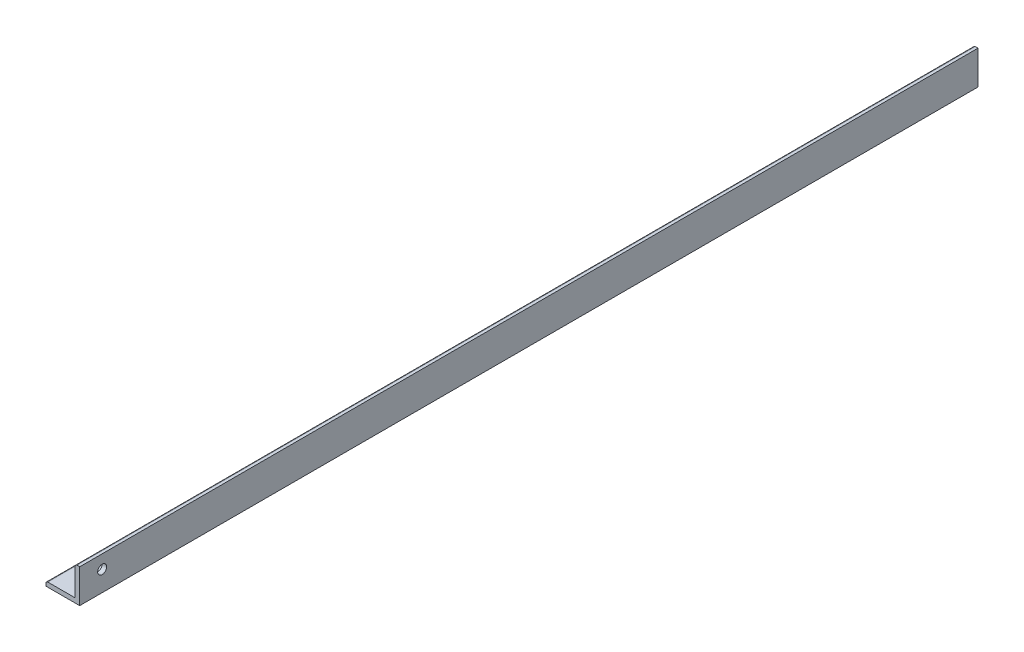
from build123d import *

# Parameters (mm, degrees)
EXTRUDE_1_DEPTH     = 400
FILLET_1_R          = 0.8
SKETCH_2_R          = 2
CUT_EXTRUDE_1_DEPTH = 2
SKETCH_3_R          = 2
CUT_EXTRUDE_2_DEPTH = 400


with BuildPart() as part:
    # 草图1 → 凸台-拉伸1 (new body)
    with BuildSketch(Plane.XY):
        Polygon((0, 0), (0, 15), (-2, 15), (-2, 2), (-15, 2), (-15, 0), align=None)
    extrude(amount=EXTRUDE_1_DEPTH)

    # 圆角1
    fillet_1_edges = [part.edges().sort_by_distance(p)[0] for p in [
        (-15, 2, 200),
        (-2, 15, 200),
    ]]
    fillet(fillet_1_edges, radius=FILLET_1_R)

    # 草图2 → 切除-拉伸1 (cut)
    with BuildSketch(Plane(origin=(0, 2, 0), x_dir=(1, 0, 0), z_dir=(0, 1, 0))):
        with Locations((-8, -222)):
            Circle(SKETCH_2_R)
    extrude(amount=-CUT_EXTRUDE_1_DEPTH, mode=Mode.SUBTRACT)

    # 草图3 → 切除-拉伸2 (cut)
    with BuildSketch(Plane.ZY.offset(2)):
        with Locations((390, 9)):
            Circle(SKETCH_3_R)
    extrude(amount=-CUT_EXTRUDE_2_DEPTH, mode=Mode.SUBTRACT)


solid = part.part
